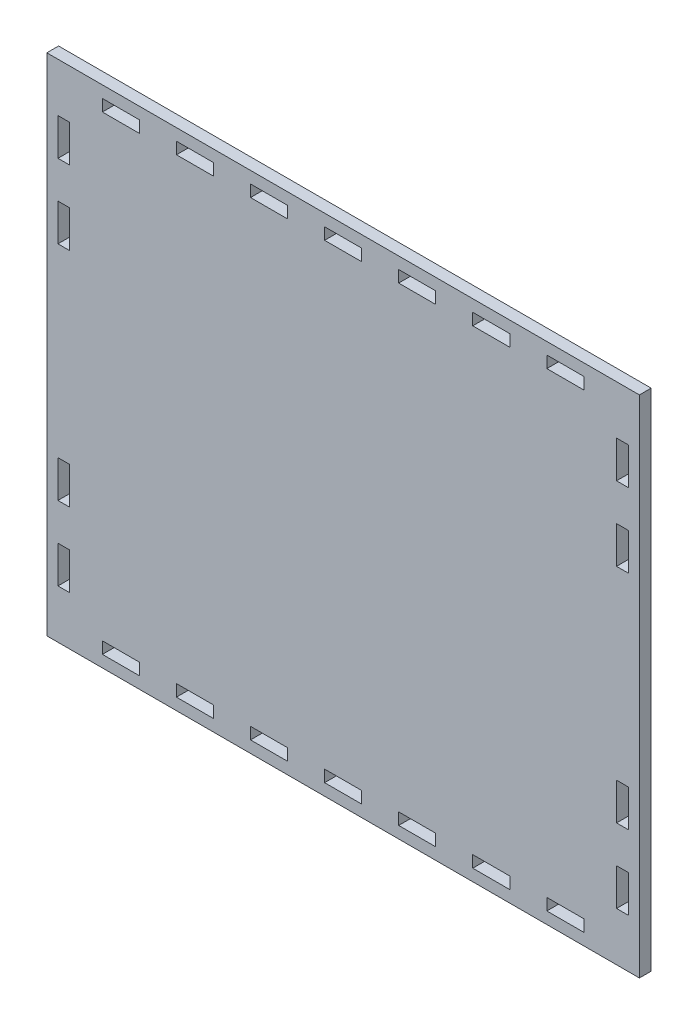
from build123d import *

# Parameters (mm, degrees)
SKETCH1_W           = 160
SKETCH1_H           = 136.35
SKETCH1_W_2         = 10
SKETCH1_H_2         = 3.175
SKETCH1_W_3         = 3.175
SKETCH1_H_3         = 10
BOSS_EXTRUDE1_DEPTH = 3.175


with BuildPart() as part:
    # Sketch1 → Boss-Extrude1 (new body)
    with BuildSketch(Plane.XY):
        with Locations((80, 68.069958461)):
            Rectangle(SKETCH1_W, SKETCH1_H)
        with Locations((40, 131.482458461)):
            Rectangle(SKETCH1_W_2, SKETCH1_H_2, mode=Mode.SUBTRACT)
        with Locations((20, 131.482458461)):
            Rectangle(SKETCH1_W_2, SKETCH1_H_2, mode=Mode.SUBTRACT)
        with Locations((60, 131.482458461)):
            Rectangle(SKETCH1_W_2, SKETCH1_H_2, mode=Mode.SUBTRACT)
        with Locations((80, 131.482458461)):
            Rectangle(SKETCH1_W_2, SKETCH1_H_2, mode=Mode.SUBTRACT)
        with Locations((100, 131.482458461)):
            Rectangle(SKETCH1_W_2, SKETCH1_H_2, mode=Mode.SUBTRACT)
        with Locations((120, 131.482458461)):
            Rectangle(SKETCH1_W_2, SKETCH1_H_2, mode=Mode.SUBTRACT)
        with Locations((140, 131.482458461)):
            Rectangle(SKETCH1_W_2, SKETCH1_H_2, mode=Mode.SUBTRACT)
        with Locations((140, 4.657458461)):
            Rectangle(SKETCH1_W_2, SKETCH1_H_2, mode=Mode.SUBTRACT)
        with Locations((120, 4.657458461)):
            Rectangle(SKETCH1_W_2, SKETCH1_H_2, mode=Mode.SUBTRACT)
        with Locations((100, 4.657458461)):
            Rectangle(SKETCH1_W_2, SKETCH1_H_2, mode=Mode.SUBTRACT)
        with Locations((80, 4.657458461)):
            Rectangle(SKETCH1_W_2, SKETCH1_H_2, mode=Mode.SUBTRACT)
        with Locations((60, 4.657458461)):
            Rectangle(SKETCH1_W_2, SKETCH1_H_2, mode=Mode.SUBTRACT)
        with Locations((40, 4.657458461)):
            Rectangle(SKETCH1_W_2, SKETCH1_H_2, mode=Mode.SUBTRACT)
        with Locations((20, 4.657458461)):
            Rectangle(SKETCH1_W_2, SKETCH1_H_2, mode=Mode.SUBTRACT)
        with Locations((4.5875, 38.069958461)):
            Rectangle(SKETCH1_W_3, SKETCH1_H_3, mode=Mode.SUBTRACT)
        with Locations((4.5875, 98.069958461)):
            Rectangle(SKETCH1_W_3, SKETCH1_H_3, mode=Mode.SUBTRACT)
        with Locations((4.5875, 118.069958461)):
            Rectangle(SKETCH1_W_3, SKETCH1_H_3, mode=Mode.SUBTRACT)
        with Locations((4.5875, 18.069958461)):
            Rectangle(SKETCH1_W_3, SKETCH1_H_3, mode=Mode.SUBTRACT)
        with Locations((155.4125, 18.069958461)):
            Rectangle(SKETCH1_W_3, SKETCH1_H_3, mode=Mode.SUBTRACT)
        with Locations((155.4125, 38.069958461)):
            Rectangle(SKETCH1_W_3, SKETCH1_H_3, mode=Mode.SUBTRACT)
        with Locations((155.4125, 98.069958461)):
            Rectangle(SKETCH1_W_3, SKETCH1_H_3, mode=Mode.SUBTRACT)
        with Locations((155.4125, 118.069958461)):
            Rectangle(SKETCH1_W_3, SKETCH1_H_3, mode=Mode.SUBTRACT)
    extrude(amount=BOSS_EXTRUDE1_DEPTH)


solid = part.part
